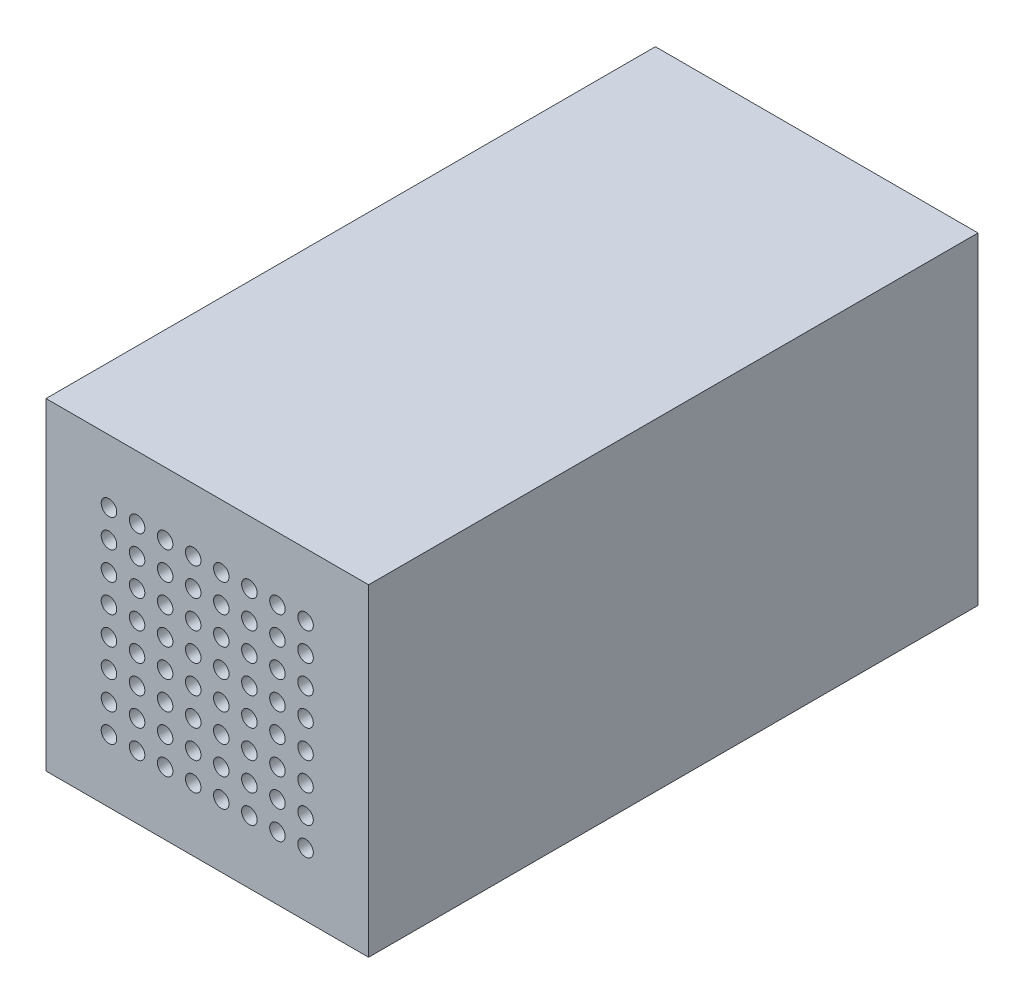
from build123d import *

# Parameters (mm, degrees)
SKETCH2_W           = 27
SKETCH2_H           = 27
BOSS_EXTRUDE1_DEPTH = 8
SKETCH5_R           = 0.65
CUT_EXTRUDE2_DEPTH  = 8
SKETCH2_6_W         = 27
SKETCH2_6_H         = 27
SKETCH2_6_W_2       = 20
SKETCH2_6_H_2       = 20
BOSS_EXTRUDE2_DEPTH = 43


with BuildPart() as part:
    # Sketch2 → Boss-Extrude1 (new body)
    with BuildSketch(Plane.XY.offset(43)):
        Rectangle(SKETCH2_W, SKETCH2_H)
    extrude(amount=BOSS_EXTRUDE1_DEPTH)

    # Sketch5 → Cut-Extrude2 (cut)
    with BuildSketch(Plane.XY.offset(43)):
        with Locations((-8.23, 8.23)):
            Circle(SKETCH5_R)
        with Locations((-5.88, 8.23)):
            Circle(SKETCH5_R)
        with Locations((-3.53, 8.23)):
            Circle(SKETCH5_R)
        with Locations((-1.18, 8.23)):
            Circle(SKETCH5_R)
        with Locations((1.17, 8.23)):
            Circle(SKETCH5_R)
        with Locations((3.52, 8.23)):
            Circle(SKETCH5_R)
        with Locations((5.87, 8.23)):
            Circle(SKETCH5_R)
        with Locations((8.22, 8.23)):
            Circle(SKETCH5_R)
        with Locations((-5.88, 5.88)):
            Circle(SKETCH5_R)
        with Locations((-3.53, 5.88)):
            Circle(SKETCH5_R)
        with Locations((-1.18, 5.88)):
            Circle(SKETCH5_R)
        with Locations((1.17, 5.88)):
            Circle(SKETCH5_R)
        with Locations((3.52, 5.88)):
            Circle(SKETCH5_R)
        with Locations((5.87, 5.88)):
            Circle(SKETCH5_R)
        with Locations((8.22, 5.88)):
            Circle(SKETCH5_R)
        with Locations((-5.88, 3.53)):
            Circle(SKETCH5_R)
        with Locations((-3.53, 3.53)):
            Circle(SKETCH5_R)
        with Locations((-1.18, 3.53)):
            Circle(SKETCH5_R)
        with Locations((1.17, 3.53)):
            Circle(SKETCH5_R)
        with Locations((3.52, 3.53)):
            Circle(SKETCH5_R)
        with Locations((5.87, 3.53)):
            Circle(SKETCH5_R)
        with Locations((8.22, 3.53)):
            Circle(SKETCH5_R)
        with Locations((-5.88, 1.18)):
            Circle(SKETCH5_R)
        with Locations((-3.53, 1.18)):
            Circle(SKETCH5_R)
        with Locations((-1.18, 1.18)):
            Circle(SKETCH5_R)
        with Locations((1.17, 1.18)):
            Circle(SKETCH5_R)
        with Locations((3.52, 1.18)):
            Circle(SKETCH5_R)
        with Locations((5.87, 1.18)):
            Circle(SKETCH5_R)
        with Locations((8.22, 1.18)):
            Circle(SKETCH5_R)
        with Locations((-5.88, -1.17)):
            Circle(SKETCH5_R)
        with Locations((-3.53, -1.17)):
            Circle(SKETCH5_R)
        with Locations((-1.18, -1.17)):
            Circle(SKETCH5_R)
        with Locations((1.17, -1.17)):
            Circle(SKETCH5_R)
        with Locations((3.52, -1.17)):
            Circle(SKETCH5_R)
        with Locations((5.87, -1.17)):
            Circle(SKETCH5_R)
        with Locations((8.22, -1.17)):
            Circle(SKETCH5_R)
        with Locations((-5.88, -3.52)):
            Circle(SKETCH5_R)
        with Locations((-3.53, -3.52)):
            Circle(SKETCH5_R)
        with Locations((-1.18, -3.52)):
            Circle(SKETCH5_R)
        with Locations((1.17, -3.52)):
            Circle(SKETCH5_R)
        with Locations((3.52, -3.52)):
            Circle(SKETCH5_R)
        with Locations((5.87, -3.52)):
            Circle(SKETCH5_R)
        with Locations((8.22, -3.52)):
            Circle(SKETCH5_R)
        with Locations((-5.88, -5.87)):
            Circle(SKETCH5_R)
        with Locations((-3.53, -5.87)):
            Circle(SKETCH5_R)
        with Locations((-1.18, -5.87)):
            Circle(SKETCH5_R)
        with Locations((1.17, -5.87)):
            Circle(SKETCH5_R)
        with Locations((3.52, -5.87)):
            Circle(SKETCH5_R)
        with Locations((5.87, -5.87)):
            Circle(SKETCH5_R)
        with Locations((8.22, -5.87)):
            Circle(SKETCH5_R)
        with Locations((-5.88, -8.22)):
            Circle(SKETCH5_R)
        with Locations((-3.53, -8.22)):
            Circle(SKETCH5_R)
        with Locations((-1.18, -8.22)):
            Circle(SKETCH5_R)
        with Locations((1.17, -8.22)):
            Circle(SKETCH5_R)
        with Locations((3.52, -8.22)):
            Circle(SKETCH5_R)
        with Locations((5.87, -8.22)):
            Circle(SKETCH5_R)
        with Locations((8.22, -8.22)):
            Circle(SKETCH5_R)
        with Locations((-8.23, 5.88)):
            Circle(SKETCH5_R)
        with Locations((-8.23, 3.53)):
            Circle(SKETCH5_R)
        with Locations((-8.23, 1.18)):
            Circle(SKETCH5_R)
        with Locations((-8.23, -1.17)):
            Circle(SKETCH5_R)
        with Locations((-8.23, -3.52)):
            Circle(SKETCH5_R)
        with Locations((-8.23, -5.87)):
            Circle(SKETCH5_R)
        with Locations((-8.23, -8.22)):
            Circle(SKETCH5_R)
    extrude(amount=CUT_EXTRUDE2_DEPTH, mode=Mode.SUBTRACT)

    # Sketch2_6 → Boss-Extrude2 (add)
    with BuildSketch(Plane.XY.offset(43)):
        Rectangle(SKETCH2_6_W, SKETCH2_6_H)
        Rectangle(SKETCH2_6_W_2, SKETCH2_6_H_2, mode=Mode.SUBTRACT)
    extrude(amount=-BOSS_EXTRUDE2_DEPTH)


solid = part.part
